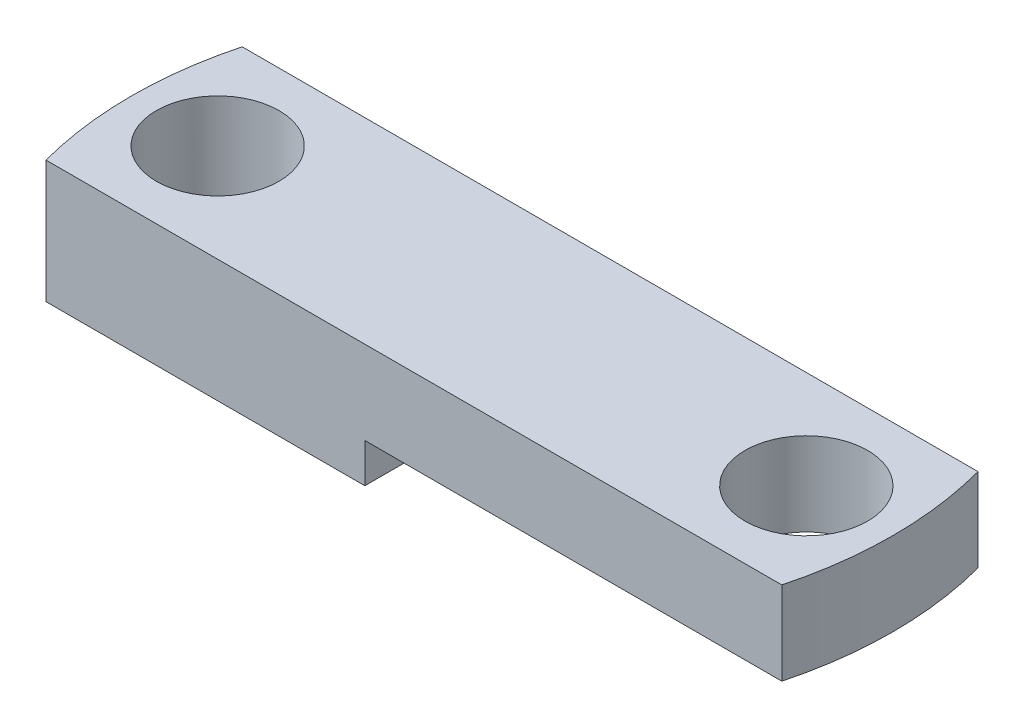
from build123d import *

# Parameters (mm, degrees)
BOSS_EXTRUDE2_DEPTH = 6.35
SKETCH4_R           = 3.175
CUT_EXTRUDE1_DEPTH  = 12.7
CUT_EXTRUDE2_DEPTH  = 2.032


with BuildPart() as part:
    # Sketch3 → Boss-Extrude2 (new body)
    with BuildSketch(Plane(origin=(0, 0, 0), x_dir=(1, 0, 0), z_dir=(0, 1, 0))):
        with BuildLine():
            Line((-19.05, 5.08), (19.05, 5.08))
            ThreePointArc((19.05, 5.08), (19.715701864, 0), (19.05, -5.08))
            Line((19.05, -5.08), (-19.05, -5.08))
            ThreePointArc((-19.05, -5.08), (-19.715701864, 0), (-19.05, 5.08))
        make_face()
    extrude(amount=BOSS_EXTRUDE2_DEPTH)

    # Sketch4 → Cut-Extrude1 (cut)
    with BuildSketch(Plane(origin=(0, 6.35, 0), x_dir=(1, 0, 0), z_dir=(0, 1, 0))):
        with Locations((15.24, 0)):
            Circle(SKETCH4_R)
        with Locations((-15.24, 0)):
            Circle(SKETCH4_R)
    extrude(amount=-CUT_EXTRUDE1_DEPTH, mode=Mode.SUBTRACT)

    # Sketch5 → Cut-Extrude2 (cut)
    with BuildSketch(Plane.XZ):
        with BuildLine():
            Line((19.05, 5.08), (-2.54, 5.08))
            Line((-2.54, 5.08), (-2.54, -5.08))
            Line((-2.54, -5.08), (19.05, -5.08))
            ThreePointArc((19.05, -5.08), (19.715701864, 0), (19.05, 5.08))
        make_face()
    extrude(amount=-CUT_EXTRUDE2_DEPTH, mode=Mode.SUBTRACT)


solid = part.part
